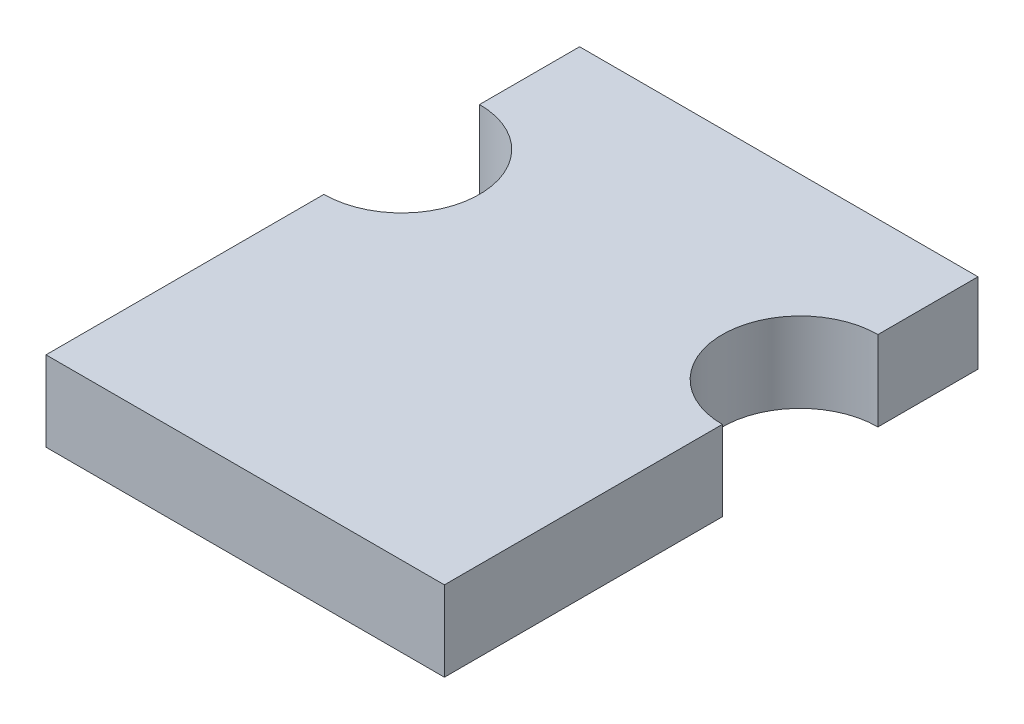
from build123d import *

# Parameters (mm, degrees)
SALIENTE_EXTRUIR1_DEPTH = 1.8


with BuildPart() as part:
    # Croquis1 → Saliente-Extruir1 (new body)
    with BuildSketch(Plane(origin=(0, 0, 0), x_dir=(1, 0, 0), z_dir=(0, 1, 0))):
        with BuildLine():
            Line((0, 0), (-8.96, 0))
            Line((-8.96, 0), (-8.96, 6.25))
            ThreePointArc((-8.96, 6.25), (-7.21, 8), (-8.96, 9.75))
            Line((-8.96, 9.75), (-8.96, 12))
            Line((-8.96, 12), (0, 12))
            Line((0, 12), (0, 9.75))
            ThreePointArc((0, 9.75), (-1.75, 8), (0, 6.25))
            Line((0, 6.25), (0, 0))
        make_face()
    extrude(amount=SALIENTE_EXTRUIR1_DEPTH)


solid = part.part
